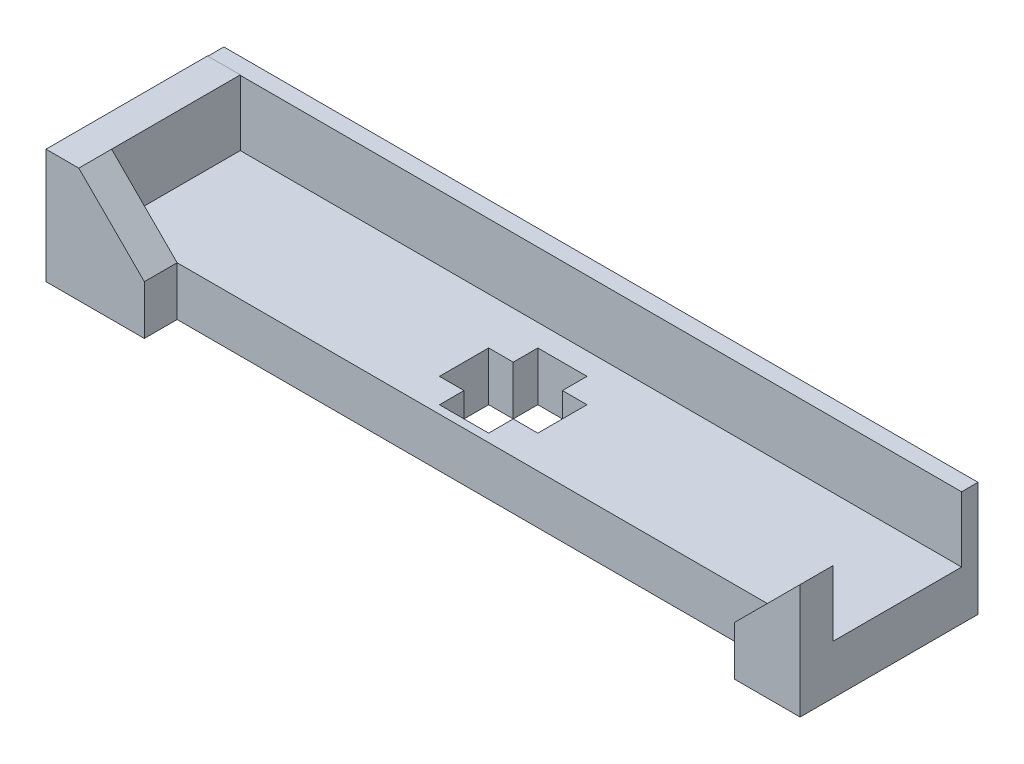
from build123d import *

# Parameters (mm, degrees)
SKETCH_1_W          = 44
SKETCH_1_H          = 7.85
EXTRUDE_1_DEPTH     = 3
SKETCH_2_W          = 7.85
SKETCH_2_H          = 7
EXTRUDE_2_DEPTH     = 2
EXTRUDE_3_DEPTH     = 2
EXTRUDE_4_DEPTH     = 2
SKETCH_5_W          = 46
SKETCH_5_H          = 6.976539996
EXTRUDE_5_DEPTH     = 1
SKETCH_6_W          = 6
SKETCH_6_H          = 3
CUT_EXTRUDE_3_DEPTH = 3
SKETCH_8_W          = 3
SKETCH_8_H          = 6
CUT_EXTRUDE_4_DEPTH = 3


with BuildPart() as part:
    # 草图1 → 凸台-拉伸1 (new body)
    with BuildSketch(Plane(origin=(0, 0, 0), x_dir=(1, 0, 0), z_dir=(0, 1, 0))):
        with Locations((-13.612906347, -10.55497291)):
            Rectangle(SKETCH_1_W, SKETCH_1_H)
    extrude(amount=EXTRUDE_1_DEPTH)

    # 草图2 → 凸台-拉伸2 (add)
    with BuildSketch(Plane.ZY.offset(35.612906347)):
        with Locations((10.55497291, 3.5)):
            Rectangle(SKETCH_2_W, SKETCH_2_H)
    extrude(amount=EXTRUDE_2_DEPTH)

    # 草图3 → 凸台-拉伸3 (add)
    with BuildSketch(Plane.XY.offset(14.47997291)):
        Polygon((-35.612906347, 7), (-31.612906347, 3), (-31.612906347, 0), (-35.612906347, 0), (-37.612906347, 0), (-37.612906347, 7), align=None)
    extrude(amount=EXTRUDE_3_DEPTH)

    # 草图4 → 凸台-拉伸4 (add)
    with BuildSketch(Plane.XY.offset(14.47997291)):
        Polygon((8.387093653, 0), (8.387093653, 7), (4.387093653, 3), (4.387093653, 0), align=None)
    extrude(amount=EXTRUDE_4_DEPTH)

    # 草图5 → 凸台-拉伸5 (add)
    with BuildSketch(Plane(origin=(0, 0, 6.62997291), x_dir=(-1, 0, 0), z_dir=(0, 0, -1))):
        with Locations((14.612906347, 3.488269998)):
            Rectangle(SKETCH_5_W, SKETCH_5_H)
    extrude(amount=EXTRUDE_5_DEPTH)

    # 草图6 → 切除-拉伸3 (cut)
    with BuildSketch(Plane.XZ):
        with Locations((-14.612906347, 10.97997291)):
            Rectangle(SKETCH_6_W, SKETCH_6_H)
    extrude(amount=-CUT_EXTRUDE_3_DEPTH, mode=Mode.SUBTRACT)

    # 草图8 → 切除-拉伸4 (cut)
    with BuildSketch(Plane.XZ):
        with Locations((-14.612906347, 10.97997291)):
            Rectangle(SKETCH_8_W, SKETCH_8_H)
    extrude(amount=-CUT_EXTRUDE_4_DEPTH, mode=Mode.SUBTRACT)


solid = part.part
